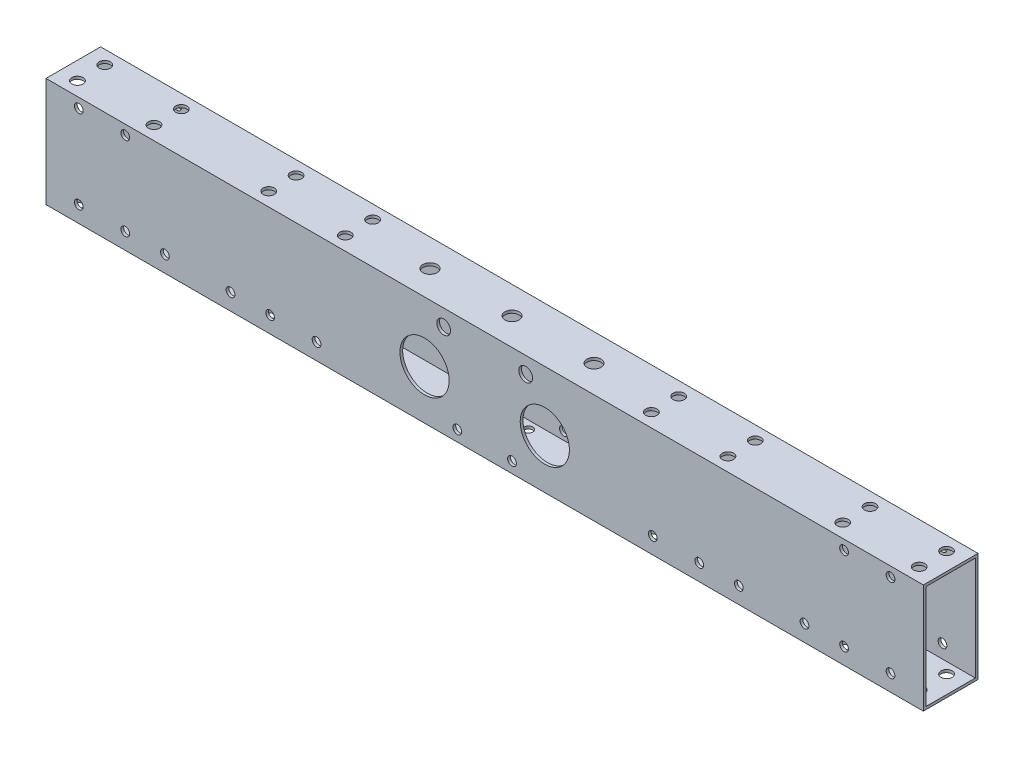
from build123d import *

# Parameters (mm, degrees)
SKETCH_1_W           = 20
SKETCH_1_H           = 40
SKETCH_1_W_2         = 18
SKETCH_1_H_2         = 38
EXTRUDE_1_DEPTH      = 321
SKETCH_2_R           = 2.05
CUT_EXTRUDE_1_DEPTH  = 41
CUT_EXTRUDE_5_REACH  = 42
SKETCH_6_R           = 1.6
CUT_EXTRUDE_9_REACH  = 42
SKETCH_12_R          = 2.6
SKETCH_14_R          = 2.05
CUT_EXTRUDE_11_DEPTH = 41
SKETCH_15_R          = 2.525
CUT_EXTRUDE_12_DEPTH = 21
SKETCH_17_R          = 1.6
CUT_EXTRUDE_13_DEPTH = 21
SKETCH_18_R          = 9
CUT_EXTRUDE_14_DEPTH = 21


with BuildPart() as part:
    # 草图1 → 凸台-拉伸1 (new body)
    with BuildSketch(Plane(origin=(0, 0, 0), x_dir=(0, 0, -1), z_dir=(1, 0, 0))):
        Rectangle(SKETCH_1_W, SKETCH_1_H)
        Rectangle(SKETCH_1_W_2, SKETCH_1_H_2, mode=Mode.SUBTRACT)
    extrude(amount=EXTRUDE_1_DEPTH)

    # 草图2 → 切除-拉伸1 (cut, through all)
    with BuildSketch(Plane(origin=(0, 20, 0), x_dir=(1, 0, 0), z_dir=(0, 1, 0))):
        with Locations((76.5, 5)):
            Circle(SKETCH_2_R)
        with Locations((76.5, -5)):
            Circle(SKETCH_2_R)
        with Locations((104.5, -5)):
            Circle(SKETCH_2_R)
        with Locations((104.5, 5)):
            Circle(SKETCH_2_R)
        with Locations((216.5, -5)):
            Circle(SKETCH_2_R)
        with Locations((216.5, 5)):
            Circle(SKETCH_2_R)
        with Locations((244.5, -5)):
            Circle(SKETCH_2_R)
        with Locations((244.5, 5)):
            Circle(SKETCH_2_R)
    extrude(amount=-CUT_EXTRUDE_1_DEPTH, mode=Mode.SUBTRACT)

    # 草图6 → 切除-拉伸5 (cut, up to next)
    with BuildSketch(Plane.XZ.offset(20), mode=Mode.PRIVATE) as cut_extrude_5_sk1:
        with Locations((140.5, 6)):
            Circle(SKETCH_6_R)
    cut_extrude_5_tool1 = extrude(cut_extrude_5_sk1.sketch, amount=-CUT_EXTRUDE_5_REACH, mode=Mode.PRIVATE) & part.part
    add(cut_extrude_5_tool1.solids().sort_by_distance((140.5, -20, 6))[0], mode=Mode.SUBTRACT)
    # 草图6 → 切除-拉伸5 (cut, up to next)
    with BuildSketch(Plane.XZ.offset(20), mode=Mode.PRIVATE) as cut_extrude_5_sk2:
        with Locations((160.5, 6)):
            Circle(SKETCH_6_R)
    cut_extrude_5_tool2 = extrude(cut_extrude_5_sk2.sketch, amount=-CUT_EXTRUDE_5_REACH, mode=Mode.PRIVATE) & part.part
    add(cut_extrude_5_tool2.solids().sort_by_distance((160.5, -20, 6))[0], mode=Mode.SUBTRACT)
    # 草图6 → 切除-拉伸5 (cut, up to next)
    with BuildSketch(Plane.XZ.offset(20), mode=Mode.PRIVATE) as cut_extrude_5_sk3:
        with Locations((180.5, 6)):
            Circle(SKETCH_6_R)
    cut_extrude_5_tool3 = extrude(cut_extrude_5_sk3.sketch, amount=-CUT_EXTRUDE_5_REACH, mode=Mode.PRIVATE) & part.part
    add(cut_extrude_5_tool3.solids().sort_by_distance((180.5, -20, 6))[0], mode=Mode.SUBTRACT)
    # 草图6 → 切除-拉伸5 (cut, up to next)
    with BuildSketch(Plane.XZ.offset(20), mode=Mode.PRIVATE) as cut_extrude_5_sk4:
        with Locations((180.5, -6)):
            Circle(SKETCH_6_R)
    cut_extrude_5_tool4 = extrude(cut_extrude_5_sk4.sketch, amount=-CUT_EXTRUDE_5_REACH, mode=Mode.PRIVATE) & part.part
    add(cut_extrude_5_tool4.solids().sort_by_distance((180.5, -20, -6))[0], mode=Mode.SUBTRACT)
    # 草图6 → 切除-拉伸5 (cut, up to next)
    with BuildSketch(Plane.XZ.offset(20), mode=Mode.PRIVATE) as cut_extrude_5_sk5:
        with Locations((160.5, -6)):
            Circle(SKETCH_6_R)
    cut_extrude_5_tool5 = extrude(cut_extrude_5_sk5.sketch, amount=-CUT_EXTRUDE_5_REACH, mode=Mode.PRIVATE) & part.part
    add(cut_extrude_5_tool5.solids().sort_by_distance((160.5, -20, -6))[0], mode=Mode.SUBTRACT)
    # 草图6 → 切除-拉伸5 (cut, up to next)
    with BuildSketch(Plane.XZ.offset(20), mode=Mode.PRIVATE) as cut_extrude_5_sk6:
        with Locations((140.5, -6)):
            Circle(SKETCH_6_R)
    cut_extrude_5_tool6 = extrude(cut_extrude_5_sk6.sketch, amount=-CUT_EXTRUDE_5_REACH, mode=Mode.PRIVATE) & part.part
    add(cut_extrude_5_tool6.solids().sort_by_distance((140.5, -20, -6))[0], mode=Mode.SUBTRACT)

    # 草图12 → 切除-拉伸9 (cut, up to next)
    with BuildSketch(Plane(origin=(0, 20, 0), x_dir=(1, 0, 0), z_dir=(0, 1, 0)), mode=Mode.PRIVATE) as cut_extrude_9_sk1:
        with Locations((130.5, 0)):
            Circle(SKETCH_12_R)
    cut_extrude_9_tool1 = extrude(cut_extrude_9_sk1.sketch, amount=-CUT_EXTRUDE_9_REACH, mode=Mode.PRIVATE) & part.part
    add(cut_extrude_9_tool1.solids().sort_by_distance((130.5, 20, 0))[0], mode=Mode.SUBTRACT)
    # 草图12 → 切除-拉伸9 (cut, up to next)
    with BuildSketch(Plane(origin=(0, 20, 0), x_dir=(1, 0, 0), z_dir=(0, 1, 0)), mode=Mode.PRIVATE) as cut_extrude_9_sk2:
        with Locations((160.5, 0)):
            Circle(SKETCH_12_R)
    cut_extrude_9_tool2 = extrude(cut_extrude_9_sk2.sketch, amount=-CUT_EXTRUDE_9_REACH, mode=Mode.PRIVATE) & part.part
    add(cut_extrude_9_tool2.solids().sort_by_distance((160.5, 20, 0))[0], mode=Mode.SUBTRACT)
    # 草图12 → 切除-拉伸9 (cut, up to next)
    with BuildSketch(Plane(origin=(0, 20, 0), x_dir=(1, 0, 0), z_dir=(0, 1, 0)), mode=Mode.PRIVATE) as cut_extrude_9_sk3:
        with Locations((190.5, 0)):
            Circle(SKETCH_12_R)
    cut_extrude_9_tool3 = extrude(cut_extrude_9_sk3.sketch, amount=-CUT_EXTRUDE_9_REACH, mode=Mode.PRIVATE) & part.part
    add(cut_extrude_9_tool3.solids().sort_by_distance((190.5, 20, 0))[0], mode=Mode.SUBTRACT)

    # 草图14 → 切除-拉伸11 (cut, through all)
    with BuildSketch(Plane(origin=(0, 20, 0), x_dir=(1, 0, 0), z_dir=(0, 1, 0))):
        with Locations((314.5, 5)):
            Circle(SKETCH_14_R)
        with Locations((314.5, -5)):
            Circle(SKETCH_14_R)
        with Locations((286.5, -5)):
            Circle(SKETCH_14_R)
        with Locations((286.5, 5)):
            Circle(SKETCH_14_R)
        with Locations((34.5, -5)):
            Circle(SKETCH_14_R)
        with Locations((6.5, -5)):
            Circle(SKETCH_14_R)
        with Locations((6.5, 5)):
            Circle(SKETCH_14_R)
        with Locations((34.5, 5)):
            Circle(SKETCH_14_R)
    extrude(amount=-CUT_EXTRUDE_11_DEPTH, mode=Mode.SUBTRACT)

    # 草图15 → 切除-拉伸12 (cut, through all)
    with BuildSketch(Plane.XY.offset(10)):
        with Locations((145.5, 14)):
            Circle(SKETCH_15_R)
        with Locations((175.5, 14)):
            Circle(SKETCH_15_R)
    extrude(amount=-CUT_EXTRUDE_12_DEPTH, mode=Mode.SUBTRACT)

    # 草图17 → 切除-拉伸13 (cut, through all)
    with BuildSketch(Plane.XY.offset(10)):
        with Locations((12, 16.5)):
            Circle(SKETCH_17_R)
        with Locations((29, 16.5)):
            Circle(SKETCH_17_R)
        with Locations((12, -14)):
            Circle(SKETCH_17_R)
        with Locations((29, -14)):
            Circle(SKETCH_17_R)
        with Locations((43.5, -14)):
            Circle(SKETCH_17_R)
        with Locations((67.5, -14)):
            Circle(SKETCH_17_R)
        with Locations((222, -14)):
            Circle(SKETCH_17_R)
        with Locations((239, -14)):
            Circle(SKETCH_17_R)
        with Locations((253.5, -14)):
            Circle(SKETCH_17_R)
        with Locations((277.5, -14)):
            Circle(SKETCH_17_R)
        with Locations((292, -14)):
            Circle(SKETCH_17_R)
        with Locations((309, -14)):
            Circle(SKETCH_17_R)
        with Locations((82, -14)):
            Circle(SKETCH_17_R)
        with Locations((99, -14)):
            Circle(SKETCH_17_R)
        with Locations((292, 16.5)):
            Circle(SKETCH_17_R)
        with Locations((309, 16.5)):
            Circle(SKETCH_17_R)
        with Locations((150.5, -16)):
            Circle(SKETCH_17_R)
        with Locations((170.5, -16)):
            Circle(SKETCH_17_R)
    extrude(amount=-CUT_EXTRUDE_13_DEPTH, mode=Mode.SUBTRACT)

    # 草图18 → 切除-拉伸14 (cut, through all)
    with BuildSketch(Plane.XY.offset(10)):
        with Locations((138.5, -2)):
            Circle(SKETCH_18_R)
        with Locations((182.5, -2)):
            Circle(SKETCH_18_R)
    extrude(amount=-CUT_EXTRUDE_14_DEPTH, mode=Mode.SUBTRACT)


solid = part.part
